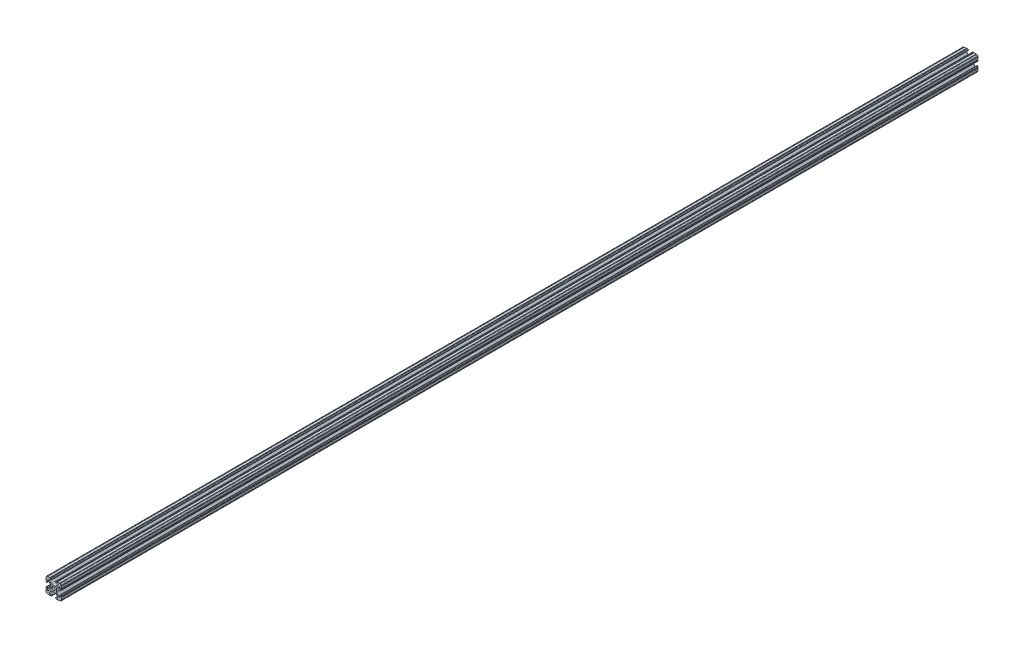
from build123d import *

# Parameters (mm, degrees)
BOSS_EXTRUDE1_DEPTH     = 762
SKETCH5_R               = 0.55245
CUT_EXTRUDE1_DEPTH      = 763
CUT_EXTRUDE1_DEPTH_BACK = 763


with BuildPart() as part:
    # Sketch4 → Boss-Extrude1 (new body, symmetric)
    with BuildSketch(Plane.XY):
        with BuildLine():
            Line((4.190365, -12.7), (10.11729625, -12.7))
            ThreePointArc((10.11729625, -12.7), (11.943543585, -11.943543585), (12.7, -10.11729625))
            Line((12.7, -10.11729625), (12.7, -4.190365))
            ThreePointArc((12.7, -4.190365), (12.42492494, -3.52627506), (11.760835, -3.2512))
            Line((11.760835, -3.2512), (11.429365, -3.2512))
            ThreePointArc((11.429365, -3.2512), (10.76527506, -3.52627506), (10.4902, -4.190365))
            Line((10.4902, -4.190365), (10.4902, -6.348478019))
            ThreePointArc((10.4902, -6.348478019), (9.830707141, -7.335478831), (8.666460301, -7.103895736))
            Line((8.666460301, -7.103895736), (5.299899128, -3.737334563))
            ThreePointArc((5.299899128, -3.737334563), (4.817571085, -3.015479634), (4.6482, -2.16399369))
            Line((4.6482, -2.16399369), (4.6482, 0))
            Line((4.6482, 0), (2.6035, 0))
            ThreePointArc((2.6035, 0), (1.840952505, -1.840952505), (0, -2.6035))
            Line((0, -2.6035), (0, -4.6482))
            Line((0, -4.6482), (2.16399369, -4.6482))
            ThreePointArc((2.16399369, -4.6482), (3.015479634, -4.817571085), (3.737334563, -5.299899128))
            Line((3.737334563, -5.299899128), (7.103895736, -8.666460301))
            ThreePointArc((7.103895736, -8.666460301), (7.335478831, -9.830707141), (6.348478019, -10.4902))
            Line((6.348478019, -10.4902), (4.190365, -10.4902))
            ThreePointArc((4.190365, -10.4902), (3.52627506, -10.76527506), (3.2512, -11.429365))
            Line((3.2512, -11.429365), (3.2512, -11.760835))
            ThreePointArc((3.2512, -11.760835), (3.52627506, -12.42492494), (4.190365, -12.7))
        make_face()
    extrude(amount=BOSS_EXTRUDE1_DEPTH, both=True)

    # Sketch5 → Cut-Extrude1 (cut, two sides)
    with BuildSketch(Plane.XY) as cut_extrude1_sk:
        with Locations((10.356153152, -12.7)):
            Circle(SKETCH5_R)
        with Locations((5.796028019, -12.7)):
            Circle(SKETCH5_R)
        with Locations((12.7, -10.356153152)):
            Circle(SKETCH5_R)
        with Locations((12.7, -5.796028019)):
            Circle(SKETCH5_R)
    extrude(amount=CUT_EXTRUDE1_DEPTH, mode=Mode.SUBTRACT)
    extrude(cut_extrude1_sk.sketch, amount=-CUT_EXTRUDE1_DEPTH_BACK, mode=Mode.SUBTRACT)

    # Mirror1: part across plane


with BuildPart() as part_1:
    add(part.part)
    add(part.part.mirror(Plane(origin=(0, 0, 0), x_dir=(0, 0, 1), z_dir=(1, 0, 0))))

    # Mirror2: part across plane


with BuildPart() as part_2:
    add(part_1.part)
    add(part_1.part.mirror(Plane.ZX))


solid = part_2.part
